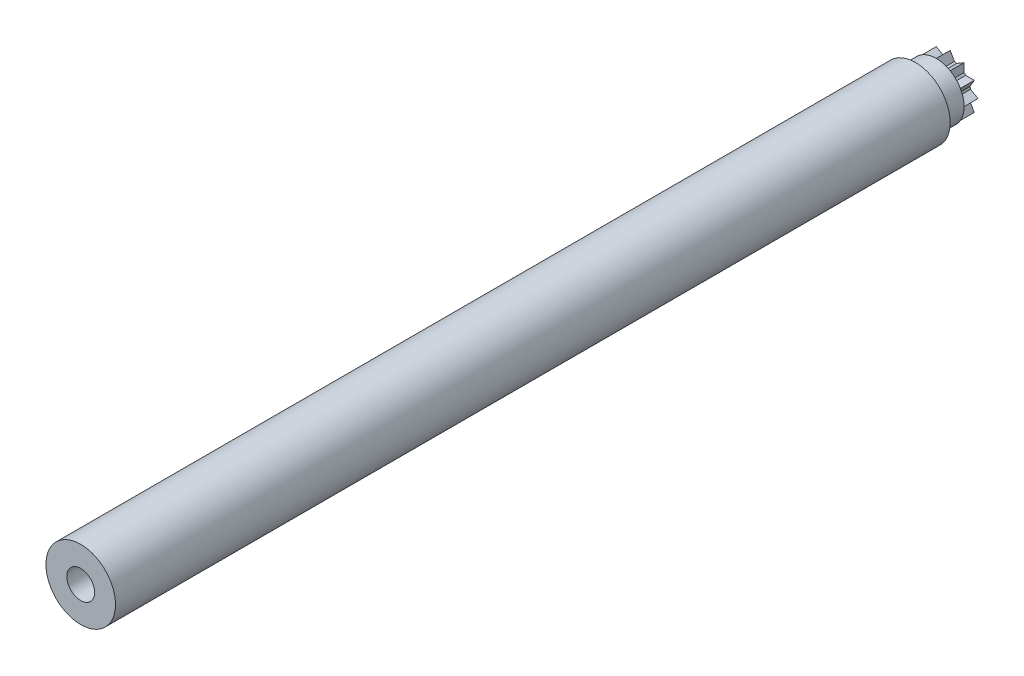
from build123d import *

# Parameters (mm, degrees)
IZIM1_R                     = 2.5
Y_KSEKLIK_EKSTR_ZYON1_DEPTH = 60
IZIM2_R                     = 2
Y_KSEKLIK_EKSTR_ZYON2_DEPTH = 2.5
KES_EKSTR_ZYON1_DEPTH       = 1
IZIM5_R                     = 1
KES_EKSTR_ZYON2_DEPTH       = 71


with BuildPart() as part:
    # Çizim1 → Yükseklik-Ekstrüzyon1 (new body)
    with BuildSketch(Plane.XY):
        Circle(IZIM1_R)
    extrude(amount=Y_KSEKLIK_EKSTR_ZYON1_DEPTH)

    # Çizim2 → Yükseklik-Ekstrüzyon2 (add)
    with BuildSketch(Plane.XY):
        Circle(IZIM2_R)
    extrude(amount=-Y_KSEKLIK_EKSTR_ZYON2_DEPTH)

    # Çizim4 → Kes-Ekstrüzyon1 (cut)
    with BuildSketch(Plane(origin=(0, 0, -2.5), x_dir=(-1, 0, 0), z_dir=(0, 0, -1))):
        with BuildLine():
            Line((-1.116104082, -1), (-1.732050808, -1))
            ThreePointArc((-1.732050808, -1), (-1.414213562, -1.414213562), (-1, -1.732050808))
            Line((-1, -1.732050808), (-1, -1.116104082))
            ThreePointArc((-1, -1.116104082), (-1.059643412, -1.059643412), (-1.116104082, -1))
        make_face()
        with BuildLine():
            Line((-0.466574488, -1.424077445), (-1, -1.732050808))
            ThreePointArc((-1, -1.732050808), (-0.51763809, -1.931851653), (0, -2))
            Line((0, -2), (-0.307973363, -1.466574488))
            ThreePointArc((-0.307973363, -1.466574488), (-0.387856408, -1.44749982), (-0.466574488, -1.424077445))
        make_face()
        with BuildLine():
            Line((0.307973363, -1.466574488), (0, -2))
            ThreePointArc((0, -2), (0.51763809, -1.931851653), (1, -1.732050808))
            Line((1, -1.732050808), (0.466574488, -1.424077445))
            ThreePointArc((0.466574488, -1.424077445), (0.387856408, -1.44749982), (0.307973363, -1.466574488))
        make_face()
        with BuildLine():
            Line((1, -1.116104082), (1, -1.732050808))
            ThreePointArc((1, -1.732050808), (1.414213562, -1.414213562), (1.732050808, -1))
            Line((1.732050808, -1), (1.116104082, -1))
            ThreePointArc((1.116104082, -1), (1.059643412, -1.059643412), (1, -1.116104082))
        make_face()
        with BuildLine():
            ThreePointArc((1.732050808, -1), (1.931851653, -0.51763809), (2, 0))
            Line((2, 0), (1.466574488, -0.307973363))
            ThreePointArc((1.466574488, -0.307973363), (1.44749982, -0.387856408), (1.424077445, -0.466574488))
            Line((1.424077445, -0.466574488), (1.732050808, -1))
        make_face()
        with BuildLine():
            ThreePointArc((2, 0), (1.931851653, 0.51763809), (1.732050808, 1))
            Line((1.732050808, 1), (1.424077445, 0.466574488))
            ThreePointArc((1.424077445, 0.466574488), (1.44749982, 0.387856408), (1.466574488, 0.307973363))
            Line((1.466574488, 0.307973363), (2, 0))
        make_face()
        with BuildLine():
            ThreePointArc((1.732050808, 1), (1.414213562, 1.414213562), (1, 1.732050808))
            Line((1, 1.732050808), (1, 1.116104082))
            ThreePointArc((1, 1.116104082), (1.059643412, 1.059643412), (1.116104082, 1))
            Line((1.116104082, 1), (1.732050808, 1))
        make_face()
        with BuildLine():
            ThreePointArc((1, 1.732050808), (0.51763809, 1.931851653), (0, 2))
            Line((0, 2), (0.307973363, 1.466574488))
            ThreePointArc((0.307973363, 1.466574488), (0.387856408, 1.44749982), (0.466574488, 1.424077445))
            Line((0.466574488, 1.424077445), (1, 1.732050808))
        make_face()
        with BuildLine():
            ThreePointArc((0, 2), (-0.51763809, 1.931851653), (-1, 1.732050808))
            Line((-1, 1.732050808), (-0.466574488, 1.424077445))
            ThreePointArc((-0.466574488, 1.424077445), (-0.387856408, 1.44749982), (-0.307973363, 1.466574488))
            Line((-0.307973363, 1.466574488), (0, 2))
        make_face()
        with BuildLine():
            ThreePointArc((-1, 1.732050808), (-1.414213562, 1.414213562), (-1.732050808, 1))
            Line((-1.732050808, 1), (-1.116104082, 1))
            ThreePointArc((-1.116104082, 1), (-1.059643412, 1.059643412), (-1, 1.116104082))
            Line((-1, 1.116104082), (-1, 1.732050808))
        make_face()
        with BuildLine():
            Line((-1.424077445, 0.466574488), (-1.732050808, 1))
            ThreePointArc((-1.732050808, 1), (-1.931851653, 0.51763809), (-2, 0))
            Line((-2, 0), (-1.466574488, 0.307973363))
            ThreePointArc((-1.466574488, 0.307973363), (-1.44749982, 0.387856408), (-1.424077445, 0.466574488))
        make_face()
        with BuildLine():
            Line((-1.466574488, -0.307973363), (-2, 0))
            ThreePointArc((-2, 0), (-1.931851653, -0.51763809), (-1.732050808, -1))
            Line((-1.732050808, -1), (-1.424077445, -0.466574488))
            ThreePointArc((-1.424077445, -0.466574488), (-1.44749982, -0.387856408), (-1.466574488, -0.307973363))
        make_face()
    extrude(amount=-KES_EKSTR_ZYON1_DEPTH, mode=Mode.SUBTRACT)

    # Çizim5 → Kes-Ekstrüzyon2 (cut)
    with BuildSketch(Plane(origin=(0, 0, -2.5), x_dir=(-1, 0, 0), z_dir=(0, 0, -1))):
        Circle(IZIM5_R)
    extrude(amount=-KES_EKSTR_ZYON2_DEPTH, mode=Mode.SUBTRACT)


solid = part.part
